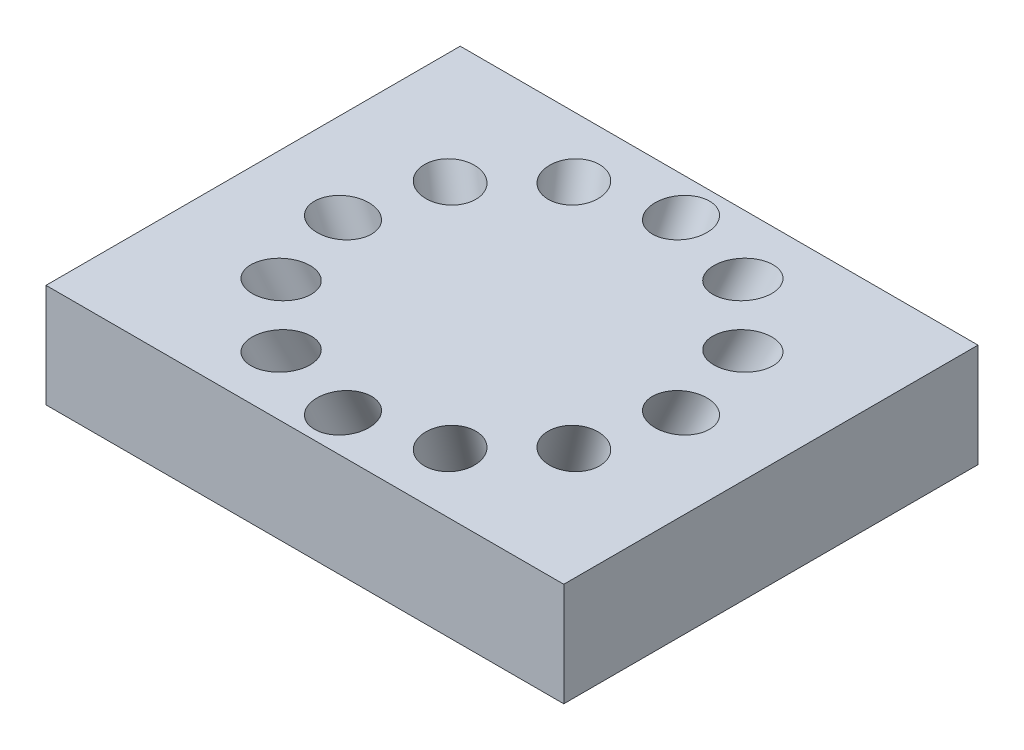
from build123d import *

# Parameters (mm, degrees)
SKIZZE1_W                       = 100
SKIZZE1_H                       = 80
AUFSATZ_LINEAR_AUSTRAGEN1_DEPTH = 20
KREISMUSTER1_COUNT              = 12


with BuildPart() as part:
    # Skizze1 → Aufsatz-Linear austragen1 (new body)
    with BuildSketch(Plane(origin=(0, 0, 0), x_dir=(1, 0, 0), z_dir=(0, 1, 0))):
        Rectangle(SKIZZE1_W, SKIZZE1_H)
    extrude(amount=AUFSATZ_LINEAR_AUSTRAGEN1_DEPTH)

    # Skizze2 → Schnitt-Rotation1 (revolve, cut)
    with BuildSketch(Plane.XY):
        Polygon((-33.62688673, 22.113091309), (-22.330032248, -2.113091309), (-17.798493313, 0), (-29.095347795, 24.226182617), align=None)
    schnitt_rotation1 = revolve(axis=Axis((0, -50, 0), (-0.422618262, 0.906307787, 0)), mode=Mode.SUBTRACT)

    # Kreismuster1: Schnitt-Rotation1 ×12 about axis
    kreismuster1_axis = Axis((0, 0, 0), (0, 1, 0))
    for i in range(1, KREISMUSTER1_COUNT):
        add(schnitt_rotation1.rotate(kreismuster1_axis, i * 360 / KREISMUSTER1_COUNT), mode=Mode.SUBTRACT)


solid = part.part
